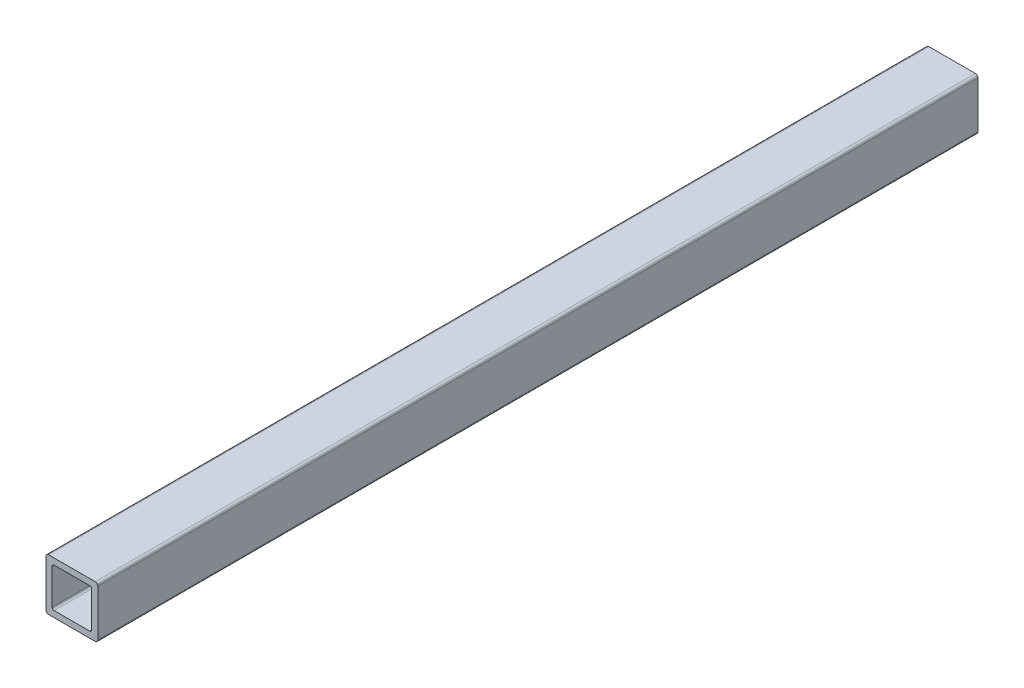
from build123d import *

# Parameters (mm, degrees)
BOSS_EXTRUDE1_DEPTH = 431.8


with BuildPart() as part:
    # Sketch4 → Boss-Extrude1 (new body)
    with BuildSketch(Plane.XY):
        with BuildLine():
            Line((12.7, -11.43), (12.7, 11.43))
            ThreePointArc((12.7, 11.43), (12.328025612, 12.328025612), (11.43, 12.7))
            Line((11.43, 12.7), (-11.43, 12.7))
            ThreePointArc((-11.43, 12.7), (-12.328025612, 12.328025612), (-12.7, 11.43))
            Line((-12.7, 11.43), (-12.7, -11.43))
            ThreePointArc((-12.7, -11.43), (-12.328025612, -12.328025612), (-11.43, -12.7))
            Line((-11.43, -12.7), (11.43, -12.7))
            ThreePointArc((11.43, -12.7), (12.328025612, -12.328025612), (12.7, -11.43))
        make_face()
        with BuildLine():
            Line((9.652, 8.6868), (9.652, -8.6868))
            ThreePointArc((9.652, -8.6868), (9.369299465, -9.369299465), (8.6868, -9.652))
            Line((8.6868, -9.652), (-8.6868, -9.652))
            ThreePointArc((-8.6868, -9.652), (-9.369299465, -9.369299465), (-9.652, -8.6868))
            Line((-9.652, -8.6868), (-9.652, 8.6868))
            ThreePointArc((-9.652, 8.6868), (-9.369299465, 9.369299465), (-8.6868, 9.652))
            Line((-8.6868, 9.652), (8.6868, 9.652))
            ThreePointArc((8.6868, 9.652), (9.369299465, 9.369299465), (9.652, 8.6868))
        make_face(mode=Mode.SUBTRACT)
    extrude(amount=BOSS_EXTRUDE1_DEPTH)


solid = part.part
